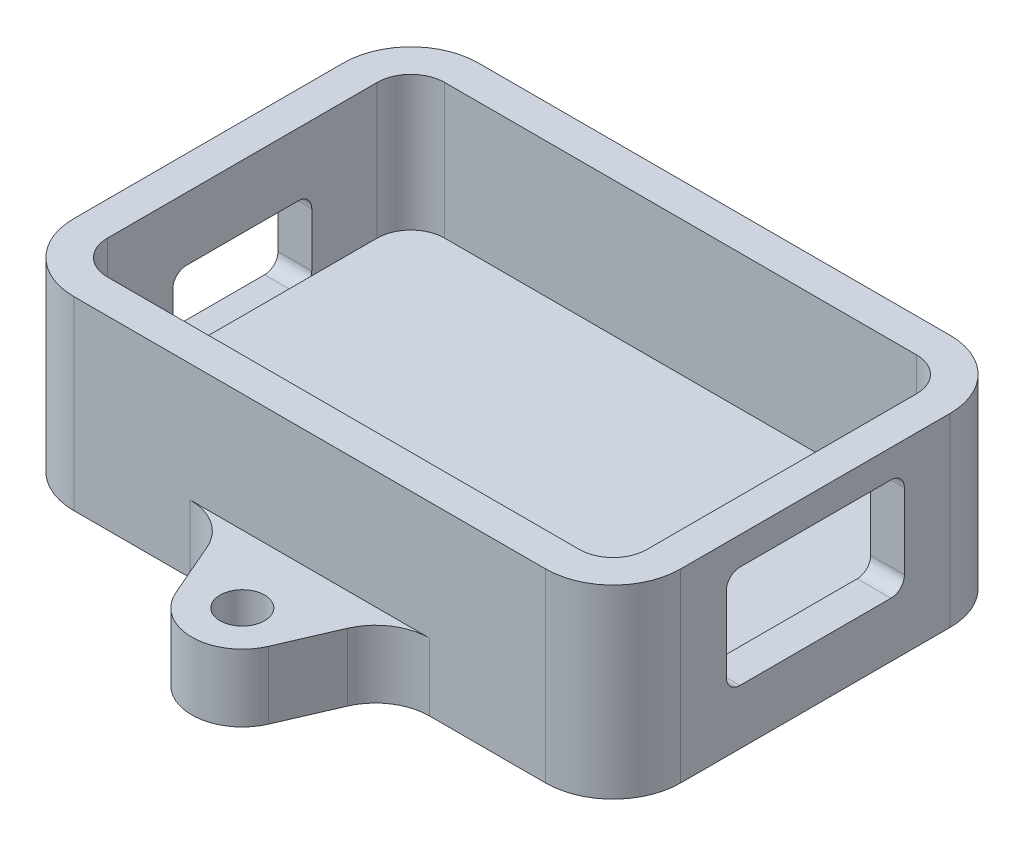
from build123d import *

# Parameters (mm, degrees)
BOSS_EXTRUDE1_DEPTH = 4.7625
BOSS_EXTRUDE2_DEPTH = 12.7
SKETCH6_R           = 2.1
BOSS_EXTRUDE3_DEPTH = 6.35
CUT_EXTRUDE1_DEPTH  = 3.175
CUT_EXTRUDE2_DEPTH  = 3.175
FILLET1_R           = 5.08


with BuildPart() as part:
    # Sketch1 → Boss-Extrude1 (new body)
    with BuildSketch(Plane(origin=(0, 0, 0), x_dir=(1, 0, 0), z_dir=(0, 1, 0))):
        with BuildLine():
            Line((-22.225, -19.05), (22.225, -19.05))
            ThreePointArc((22.225, -19.05), (26.715128061, -17.190128061), (28.575, -12.7))
            Line((28.575, -12.7), (28.575, 12.7))
            ThreePointArc((28.575, 12.7), (26.715128061, 17.190128061), (22.225, 19.05))
            Line((22.225, 19.05), (-22.225, 19.05))
            ThreePointArc((-22.225, 19.05), (-26.715128061, 17.190128061), (-28.575, 12.7))
            Line((-28.575, 12.7), (-28.575, -12.7))
            ThreePointArc((-28.575, -12.7), (-26.715128061, -17.190128061), (-22.225, -19.05))
        make_face()
    extrude(amount=BOSS_EXTRUDE1_DEPTH)

    # Sketch2 → Boss-Extrude2 (add)
    with BuildSketch(Plane(origin=(0, 4.7625, 0), x_dir=(1, 0, 0), z_dir=(0, 1, 0))):
        with BuildLine():
            Line((-22.225, -19.05), (22.225, -19.05))
            ThreePointArc((22.225, -19.05), (26.715128061, -17.190128061), (28.575, -12.7))
            Line((28.575, -12.7), (28.575, 12.7))
            ThreePointArc((28.575, 12.7), (26.715128061, 17.190128061), (22.225, 19.05))
            Line((22.225, 19.05), (-22.225, 19.05))
            ThreePointArc((-22.225, 19.05), (-26.715128061, 17.190128061), (-28.575, 12.7))
            Line((-28.575, 12.7), (-28.575, -12.7))
            ThreePointArc((-28.575, -12.7), (-26.715128061, -17.190128061), (-22.225, -19.05))
        make_face()
        with BuildLine():
            Line((-22.225, -15.875), (22.225, -15.875))
            ThreePointArc((22.225, -15.875), (24.47006403, -14.94506403), (25.4, -12.7))
            Line((25.4, -12.7), (25.4, 12.7))
            ThreePointArc((25.4, 12.7), (24.47006403, 14.94506403), (22.225, 15.875))
            Line((22.225, 15.875), (-22.225, 15.875))
            ThreePointArc((-22.225, 15.875), (-24.47006403, 14.94506403), (-25.4, 12.7))
            Line((-25.4, 12.7), (-25.4, -12.7))
            ThreePointArc((-25.4, -12.7), (-24.47006403, -14.94506403), (-22.225, -15.875))
        make_face(mode=Mode.SUBTRACT)
    extrude(amount=BOSS_EXTRUDE2_DEPTH)

    # Sketch6 → Boss-Extrude3 (add)
    with BuildSketch(Plane.XZ):
        with BuildLine():
            Line((4.370745694, -27.291557117), (7.9375, -19.05))
            Line((7.9375, -19.05), (-7.9375, -19.05))
            Line((-7.9375, -19.05), (-4.370745694, -27.291557117))
            ThreePointArc((-4.370745694, -27.291557117), (0, -30.1625), (4.370745694, -27.291557117))
        make_face()
        with Locations((0, -25.4)):
            Circle(SKETCH6_R, mode=Mode.SUBTRACT)
    boss_extrude3 = extrude(amount=-BOSS_EXTRUDE3_DEPTH)

    # Sketch4 → Cut-Extrude1 (cut)
    with BuildSketch(Plane.ZY.offset(28.575)):
        with BuildLine():
            Line((-5.2705, 3.8989), (5.2705, 3.8989))
            ThreePointArc((5.2705, 3.8989), (6.168525612, 4.270874388), (6.5405, 5.1689))
            Line((6.5405, 5.1689), (6.5405, 10.2489))
            ThreePointArc((6.5405, 10.2489), (6.168525612, 11.146925612), (5.2705, 11.5189))
            Line((5.2705, 11.5189), (-5.2705, 11.5189))
            ThreePointArc((-5.2705, 11.5189), (-6.168525612, 11.146925612), (-6.5405, 10.2489))
            Line((-6.5405, 10.2489), (-6.5405, 5.1689))
            ThreePointArc((-6.5405, 5.1689), (-6.168525612, 4.270874388), (-5.2705, 3.8989))
        make_face()
    extrude(amount=-CUT_EXTRUDE1_DEPTH, mode=Mode.SUBTRACT)

    # Sketch5 → Cut-Extrude2 (cut)
    with BuildSketch(Plane(origin=(28.575, 0, 0), x_dir=(0, 0, -1), z_dir=(1, 0, 0))):
        with BuildLine():
            Line((-7.112, 5.1689), (7.112, 5.1689))
            ThreePointArc((7.112, 5.1689), (8.010025612, 5.540874388), (8.382, 6.4389))
            Line((8.382, 6.4389), (8.382, 13.5509))
            ThreePointArc((8.382, 13.5509), (8.010025612, 14.448925612), (7.112, 14.8209))
            Line((7.112, 14.8209), (-7.112, 14.8209))
            ThreePointArc((-7.112, 14.8209), (-8.010025612, 14.448925612), (-8.382, 13.5509))
            Line((-8.382, 13.5509), (-8.382, 6.4389))
            ThreePointArc((-8.382, 6.4389), (-8.010025612, 5.540874388), (-7.112, 5.1689))
        make_face()
    extrude(amount=-CUT_EXTRUDE2_DEPTH, mode=Mode.SUBTRACT)

    # Mirror3: Boss-Extrude3 across plane
    add(boss_extrude3.mirror(Plane.XY))

    # Fillet1
    fillet1_edges = [part.edges().sort_by_distance(p)[0] for p in [
        (7.9375, 3.175, 19.05),
        (-7.9375, 3.175, 19.05),
        (-7.9375, 3.175, -19.05),
        (7.9375, 3.175, -19.05),
    ]]
    fillet(fillet1_edges, radius=FILLET1_R)


solid = part.part
